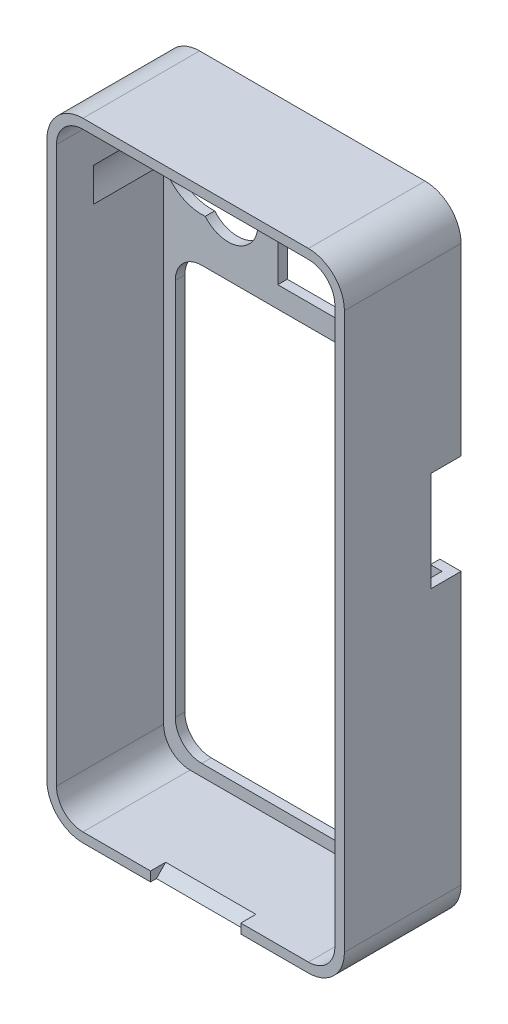
from build123d import *

# Parameters (mm, degrees)
BOSS_EXTRUDE1_DEPTH = 6.999999996
SKETCH2_R           = 7.875521796
BOSS_EXTRUDE2_DEPTH = 15.032422661
SKETCH3_R           = 5.636
SKETCH3_W           = 29.8
SKETCH3_H           = 21.2
CUT_EXTRUDE1_DEPTH  = 6.88
CUT_EXTRUDE2_DEPTH  = 13.232422661
SKETCH5_W           = 6.5
SKETCH5_H           = 18.860946171
CUT_EXTRUDE3_DEPTH  = 6.88
CUT_EXTRUDE4_DEPTH  = 8.52


with BuildPart() as part:
    # Sketch1 → Boss-Extrude1 (new body)
    with BuildSketch(Plane.XY):
        with BuildLine():
            Line((64.993664433, 62.013874967), (64.993664433, 166.948874967))
            ThreePointArc((64.993664433, 166.948874967), (63.001990545, 171.757201079), (58.193664433, 173.748874967))
            Line((58.193664433, 173.748874967), (15.615664433, 173.748874967))
            ThreePointArc((15.615664433, 173.748874967), (10.807338321, 171.757201079), (8.815664433, 166.948874967))
            Line((8.815664433, 166.948874967), (8.815664433, 62.013874967))
            ThreePointArc((8.815664433, 62.013874967), (10.807338321, 57.205548855), (15.615664433, 55.213874967))
            Line((15.615664433, 55.213874967), (58.193664433, 55.213874967))
            ThreePointArc((58.193664433, 55.213874967), (63.001990545, 57.205548855), (64.993664433, 62.013874967))
        make_face()
        with BuildLine():
            Line((63.193664433, 62.013874967), (63.193664433, 166.948874967))
            ThreePointArc((63.193664433, 166.948874967), (61.729198339, 170.484408873), (58.193664433, 171.948874967))
            Line((58.193664433, 171.948874967), (15.615664433, 171.948874967))
            ThreePointArc((15.615664433, 171.948874967), (12.080130527, 170.484408873), (10.615664433, 166.948874967))
            Line((10.615664433, 166.948874967), (10.615664433, 62.013874967))
            ThreePointArc((10.615664433, 62.013874967), (12.080130527, 58.478341061), (15.615664433, 57.013874967))
            Line((15.615664433, 57.013874967), (58.193664433, 57.013874967))
            ThreePointArc((58.193664433, 57.013874967), (61.729198339, 58.478341061), (63.193664433, 62.013874967))
        make_face(mode=Mode.SUBTRACT)
    extrude(amount=-BOSS_EXTRUDE1_DEPTH)

    # Sketch2 → Boss-Extrude2 (add)
    with BuildSketch(Plane(origin=(0, 0, -6.999999996), x_dir=(-1, 0, 0), z_dir=(0, 0, -1))):
        with BuildLine():
            Line((-58.193664433, 55.213874967), (-15.615664433, 55.213874967))
            ThreePointArc((-15.615664433, 55.213874967), (-10.807338321, 57.205548855), (-8.815664433, 62.013874967))
            Line((-8.815664433, 62.013874967), (-8.815664433, 166.948874967))
            ThreePointArc((-8.815664433, 166.948874967), (-10.807338321, 171.757201079), (-15.615664433, 173.748874967))
            Line((-15.615664433, 173.748874967), (-58.193664433, 173.748874967))
            ThreePointArc((-58.193664433, 173.748874967), (-63.001990545, 171.757201079), (-64.993664433, 166.948874967))
            Line((-64.993664433, 166.948874967), (-64.993664433, 62.013874967))
            ThreePointArc((-64.993664433, 62.013874967), (-63.001990545, 57.205548855), (-58.193664433, 55.213874967))
        make_face()
        with Locations(Location((-17.816098985, 156.86861317, 0), (0, 0, 90))):
            Circle(SKETCH2_R, mode=Mode.SUBTRACT)
    extrude(amount=BOSS_EXTRUDE2_DEPTH)

    # Sketch3 → Cut-Extrude1 (cut)
    with BuildSketch(Plane(origin=(0, 0, -22.032422657), x_dir=(-1, 0, 0), z_dir=(0, 0, -1))):
        with Locations((-22.802237874, 152.631613686)):
            Circle(SKETCH3_R)
        with BuildLine():
            Line((-60.993664433, 135.686808525), (-60.993664433, 64.213874967))
            ThreePointArc((-60.993664433, 64.213874967), (-59.529198339, 60.678341061), (-55.993664433, 59.213874967))
            Line((-55.993664433, 59.213874967), (-17.815664433, 59.213874967))
            ThreePointArc((-17.815664433, 59.213874967), (-14.280130527, 60.678341061), (-12.815664433, 64.213874967))
            Line((-12.815664433, 64.213874967), (-12.815664433, 135.686808525))
            ThreePointArc((-12.815664433, 135.686808525), (-14.280130527, 139.222342431), (-17.815664433, 140.686808525))
            Line((-17.815664433, 140.686808525), (-55.993664433, 140.686808525))
            ThreePointArc((-55.993664433, 140.686808525), (-59.529198339, 139.222342431), (-60.993664433, 135.686808525))
        make_face()
        with Locations((-47.079251594, 155.286808525)):
            Rectangle(SKETCH3_W, SKETCH3_H)
    extrude(amount=-CUT_EXTRUDE1_DEPTH, mode=Mode.SUBTRACT)

    # Sketch4 → Cut-Extrude2 (cut)
    with BuildSketch(Plane.XY.offset(-6.999999996)):
        with BuildLine():
            Line((15.615664433, 57.013874967), (58.193664433, 57.013874967))
            ThreePointArc((58.193664433, 57.013874967), (61.729198339, 58.478341061), (63.193664433, 62.013874967))
            Line((63.193664433, 62.013874967), (63.193664433, 166.948874967))
            ThreePointArc((63.193664433, 166.948874967), (61.729198339, 170.484408873), (58.193664433, 171.948874967))
            Line((58.193664433, 171.948874967), (15.615664433, 171.948874967))
            ThreePointArc((15.615664433, 171.948874967), (12.080130527, 170.484408873), (10.615664433, 166.948874967))
            Line((10.615664433, 166.948874967), (10.615664433, 160.058846048))
            ThreePointArc((10.615664433, 160.058846048), (25.691620781, 156.86861317), (10.615664433, 153.678380292))
            Line((10.615664433, 153.678380292), (10.615664433, 62.013874967))
            ThreePointArc((10.615664433, 62.013874967), (12.080130527, 58.478341061), (15.615664433, 57.013874967))
        make_face()
    extrude(amount=-CUT_EXTRUDE2_DEPTH, mode=Mode.SUBTRACT)

    # Sketch5 → Cut-Extrude3 (cut)
    with BuildSketch(Plane(origin=(64.993664433, 0, 0), x_dir=(0, 0, -1), z_dir=(1, 0, 0))):
        with Locations((19.582422658, 122.741984607)):
            Rectangle(SKETCH5_W, SKETCH5_H)
    extrude(amount=-CUT_EXTRUDE3_DEPTH, mode=Mode.SUBTRACT)

    # Sketch6 → Cut-Extrude4 (cut, symmetric)
    with BuildSketch(Plane.ZY.offset(-36.904664433)):
        Polygon((0, 57.013874967), (-2.853568486, 57.013874967), (-1.108049312, 55.213874967), (0, 55.213874967), align=None)
    extrude(amount=CUT_EXTRUDE4_DEPTH, both=True, mode=Mode.SUBTRACT)


solid = part.part
